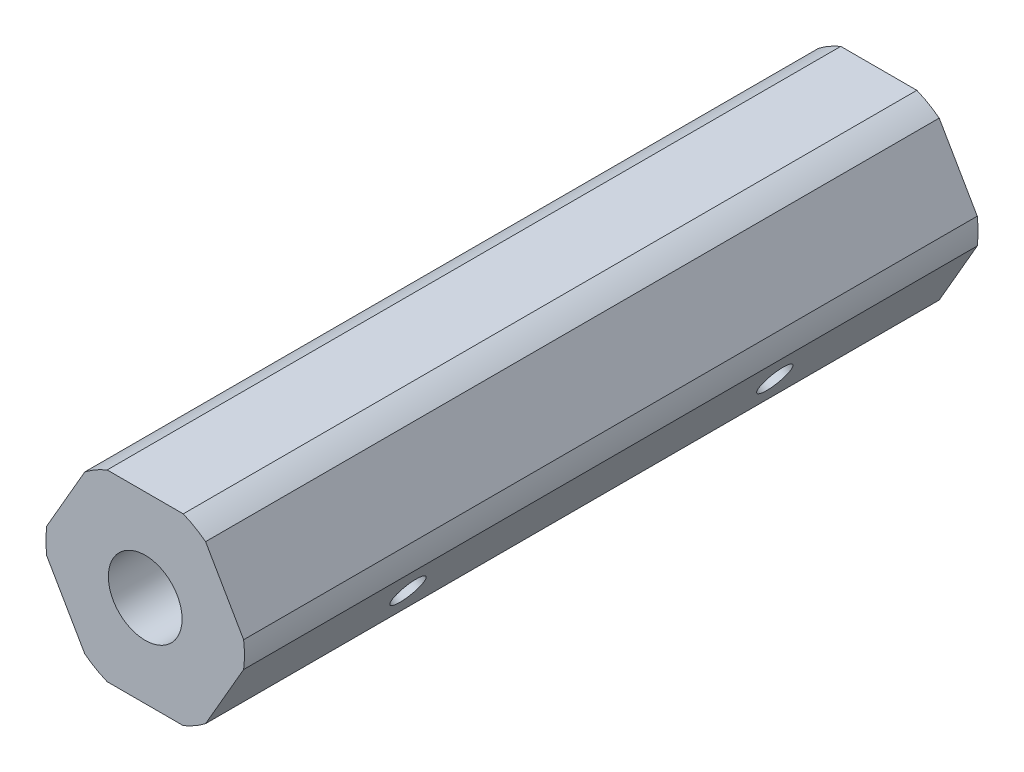
from build123d import *

# Parameters (mm, degrees)
BOSS_EXTRUDE1_DEPTH     = 25.4
F_1_4_20_TAPPED_HOLE1_D = 5.1054
F_4_40_TAPPED_HOLE1_D   = 2.2606
F_4_40_TAPPED_HOLE2_D   = 2.2606


with BuildPart() as part:
    # Sketch1 → Boss-Extrude1 (new body, symmetric)
    with BuildSketch(Plane.XY):
        with BuildLine():
            Line((-2.634981025, -6.35), (2.634981025, -6.35))
            ThreePointArc((2.634981025, -6.35), (3.4375, -5.953924651), (4.181770802, -5.456960506))
            Line((4.181770802, -5.456960506), (6.816751826, -0.893039494))
            ThreePointArc((6.816751826, -0.893039494), (6.875, 0), (6.816751826, 0.893039494))
            Line((6.816751826, 0.893039494), (4.181770802, 5.456960506))
            ThreePointArc((4.181770802, 5.456960506), (3.4375, 5.953924651), (2.634981025, 6.35))
            Line((2.634981025, 6.35), (-2.634981025, 6.35))
            ThreePointArc((-2.634981025, 6.35), (-3.4375, 5.953924651), (-4.181770802, 5.456960506))
            Line((-4.181770802, 5.456960506), (-6.816751826, 0.893039494))
            ThreePointArc((-6.816751826, 0.893039494), (-6.875, 0), (-6.816751826, -0.893039494))
            Line((-6.816751826, -0.893039494), (-4.181770802, -5.456960506))
            ThreePointArc((-4.181770802, -5.456960506), (-3.4375, -5.953924651), (-2.634981025, -6.35))
        make_face()
    extrude(amount=BOSS_EXTRUDE1_DEPTH, both=True)

    # 1/4-20 Tapped Hole1 (through all)
    with Locations(Plane.XY.offset(25.4)):
        with Locations((0, 0)):
            Hole(F_1_4_20_TAPPED_HOLE1_D / 2)

    # #4-40 Tapped Hole1 (through all)
    with Locations(Plane(origin=(0.736761314, -11.423891971, -31.75), x_dir=(0, 0, -1), z_dir=(0.866025404, -0.5, 0))):
        with Locations((-44.45, 120.65), (-19.05, 120.65), (-19.05, 9.525), (-44.45, 9.525)):
            Hole(F_4_40_TAPPED_HOLE1_D / 2)

    # #4-40 Tapped Hole2 (through all)
    with Locations(Plane(origin=(-54.825738686, -107.660964967, -31.75), x_dir=(0, 0, -1), z_dir=(0.866025404, -0.5, 0))):
        with Locations((-44.45, 120.65), (-19.05, 120.65), (-19.05, 9.525), (-44.45, 9.525)):
            Hole(F_4_40_TAPPED_HOLE2_D / 2)


solid = part.part
